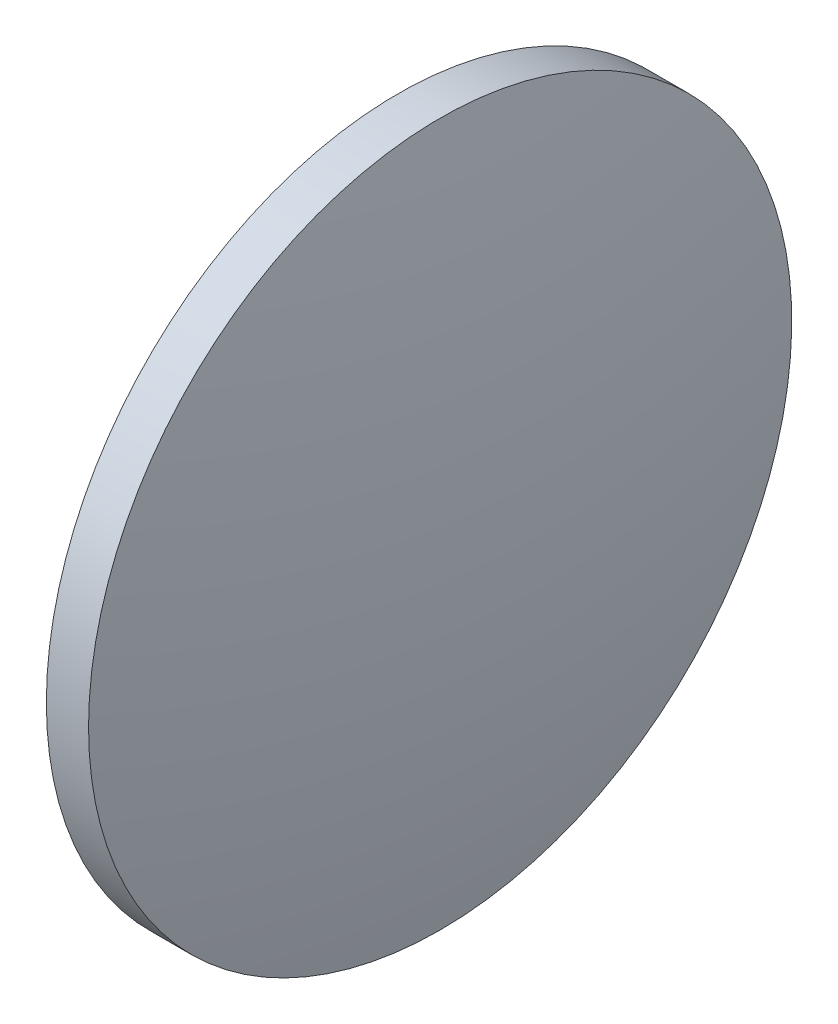
from build123d import *


with BuildPart() as part:
    # 草图1 → 旋转1 (revolve)
    with BuildSketch(Plane.XY, mode=Mode.PRIVATE) as revolve_1_sk:
        with BuildLine():
            Line((452.271181677, -45.578362358), (452.271181677, -20.578362358))
            Line((452.271181677, -20.578362358), (455.271181677, -20.578362358))
            ThreePointArc((455.271181677, -20.578362358), (457.099735877, -33.018967468), (457.711181677, -45.578362358))
            Line((457.711181677, -45.578362358), (452.271181677, -45.578362358))
        make_face()
    revolve(revolve_1_sk.sketch.rotate(Axis((448.126169928, -45.578362358, 0), (1, 0, 0)), 180), axis=Axis((448.126169928, -45.578362358, 0), (1, 0, 0)))  # turned: the seam where the file's is


solid = part.part
